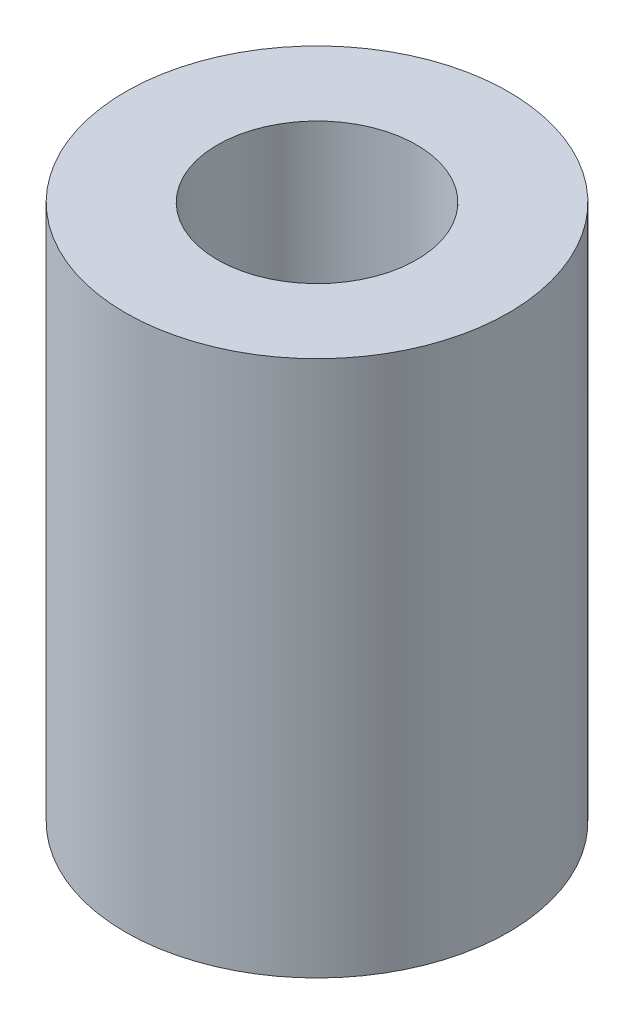
from build123d import *

# Parameters (mm, degrees)
SKETCH1_R           = 5
SKETCH1_R_2         = 2.6
BOSS_EXTRUDE1_DEPTH = 14


with BuildPart() as part:
    # Sketch1 → Boss-Extrude1 (new body)
    with BuildSketch(Plane(origin=(0, 0, 0), x_dir=(1, 0, 0), z_dir=(0, 1, 0))):
        Circle(SKETCH1_R)
        Circle(SKETCH1_R_2, mode=Mode.SUBTRACT)
    extrude(amount=BOSS_EXTRUDE1_DEPTH)


solid = part.part
